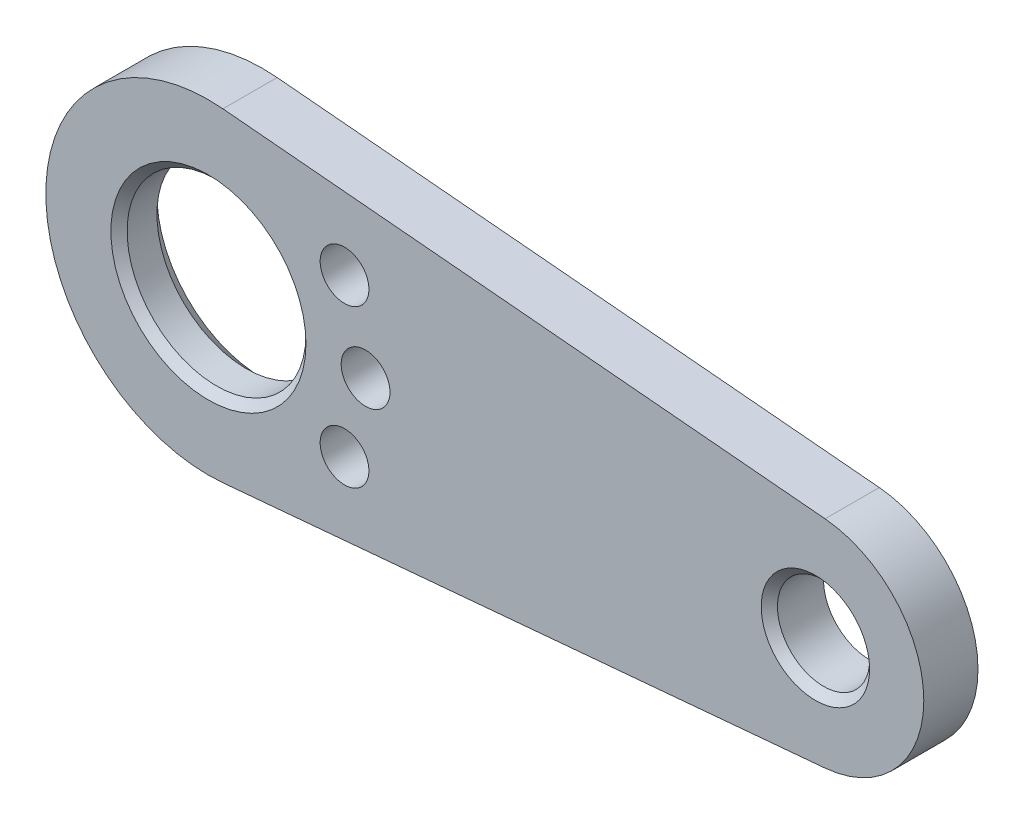
from build123d import *

# Parameters (mm, degrees)
BOSS_EXTRUDE1_DEPTH            = 1
SKETCH2_R                      = 1.65
SKETCH2_R_2                    = 0.85
CUT_EXTRUDE1_DEPTH             = 2
CHAMFER1_SIZE                  = 0.15
CHAMFER2_SIZE                  = 0.3
F_0_9_0_9_DIAMETER_HOLE1_D     = 0.9
F_0_9_0_9_DIAMETER_HOLE1_DEPTH = 1


with BuildPart() as part:
    # Sketch1 → Boss-Extrude1 (new body)
    with BuildSketch(Plane.XY):
        with BuildLine():
            Line((0.267857143, 2.988018164), (11.378571429, 1.99201211))
            ThreePointArc((11.378571429, 1.99201211), (13.2, 0), (11.378571429, -1.99201211))
            Line((11.378571429, -1.99201211), (0.267857143, -2.988018164))
            ThreePointArc((0.267857143, -2.988018164), (-3, 0), (0.267857143, 2.988018164))
        make_face()
    extrude(amount=-BOSS_EXTRUDE1_DEPTH)

    # Sketch2 → Cut-Extrude1 (cut, through all)
    with BuildSketch(Plane.XY):
        Circle(SKETCH2_R)
        with Locations((11.2, 0)):
            Circle(SKETCH2_R_2)
    extrude(amount=-CUT_EXTRUDE1_DEPTH, mode=Mode.SUBTRACT)

    # Chamfer1
    chamfer1_edges = [part.edges().sort_by_distance(p)[0] for p in [
        (-1.65, 0, 0),
        (10.35, 0, 0),
    ]]
    chamfer(chamfer1_edges, length=CHAMFER1_SIZE)

    # Chamfer2
    chamfer2_edges = [part.edges().sort_by_distance(p)[0] for p in [
        (-1.65, 0, -1),
    ]]
    chamfer(chamfer2_edges, length=CHAMFER2_SIZE)

    # Ø0.9 (0.9) Diameter Hole1
    with Locations(Plane.XY):
        with Locations((2.9, 0), (2.511473671, 1.45), (2.511473671, -1.45)):
            Hole(F_0_9_0_9_DIAMETER_HOLE1_D / 2, depth=F_0_9_0_9_DIAMETER_HOLE1_DEPTH)


solid = part.part
